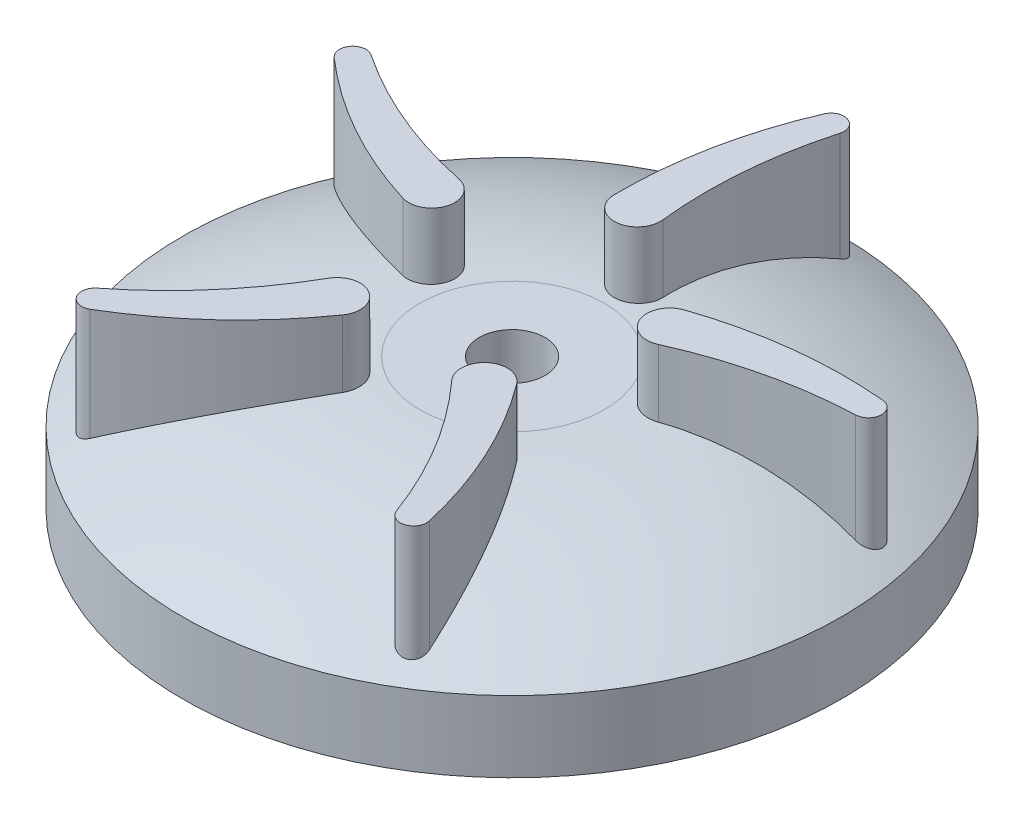
from build123d import *

# Parameters (mm, degrees)
ODEBRAT_VYSUNUT_M1_REACH = 22
SKICA2_R                 = 5
P_IDAT_START             = -7.597862
P_IDAT_VYSUNUT_M1_DEPTH  = 17.597862
KRUHOV_POLE1_COUNT       = 5


with BuildPart() as part:
    # Skica1 → Rotovat1 (revolve)
    with BuildSketch(Plane.XY):
        with BuildLine():
            Line((0, 0), (0, 20))
            Line((0, 20), (14, 20))
            ThreePointArc((14, 20), (32.579084411, 17.662353543), (50, 10.795136598))
            Line((50, 10.795136598), (50, 0))
            Line((50, 0), (0, 0))
        make_face()
    revolve(axis=Axis((0, 0, 0), (0, 1, 0)))

    # Skica2 → Odebrat vysunutím1 (cut, up to next)
    with BuildSketch(Plane(origin=(0, 20, 0), x_dir=(1, 0, 0), z_dir=(0, 1, 0)), mode=Mode.PRIVATE) as odebrat_vysunut_m1_sk1:
        Circle(SKICA2_R)
    odebrat_vysunut_m1_tool1 = extrude(odebrat_vysunut_m1_sk1.sketch, amount=-ODEBRAT_VYSUNUT_M1_REACH, mode=Mode.PRIVATE) & part.part
    add(odebrat_vysunut_m1_tool1.solids().sort_by_distance((0, 20, 0))[0], mode=Mode.SUBTRACT)

    # Skica3 → Přidat vysunutím1 (add)
    with BuildSketch(Plane(origin=(0, 20, 0), x_dir=(1, 0, 0), z_dir=(0, 1, 0)).offset(P_IDAT_START)):
        with BuildLine():
            ThreePointArc((5.542949714, 44.202455598), (4.287230231, 46.631857241), (1.78118303, 45.537073612))
            ThreePointArc((1.78118303, 45.537073612), (-2.260445719, 32.522428192), (-3.499658814, 18.951130934))
            ThreePointArc((-3.499658814, 18.951130934), (0.216435534, 15.506698459), (3.478925663, 19.383505191))
            ThreePointArc((3.478925663, 19.383505191), (3.31115986, 31.892757792), (5.542949714, 44.202455598))
        make_face()
    p_idat_vysunut_m1 = extrude(amount=P_IDAT_VYSUNUT_M1_DEPTH)

    # Kruhové pole1: Přidat vysunutím1 ×5 about axis
    kruhov_pole1_axis = Axis((0, 0, 0), (0, 1, 0))
    for i in range(1, KRUHOV_POLE1_COUNT):
        add(p_idat_vysunut_m1.rotate(kruhov_pole1_axis, i * 360 / KRUHOV_POLE1_COUNT))


solid = part.part
